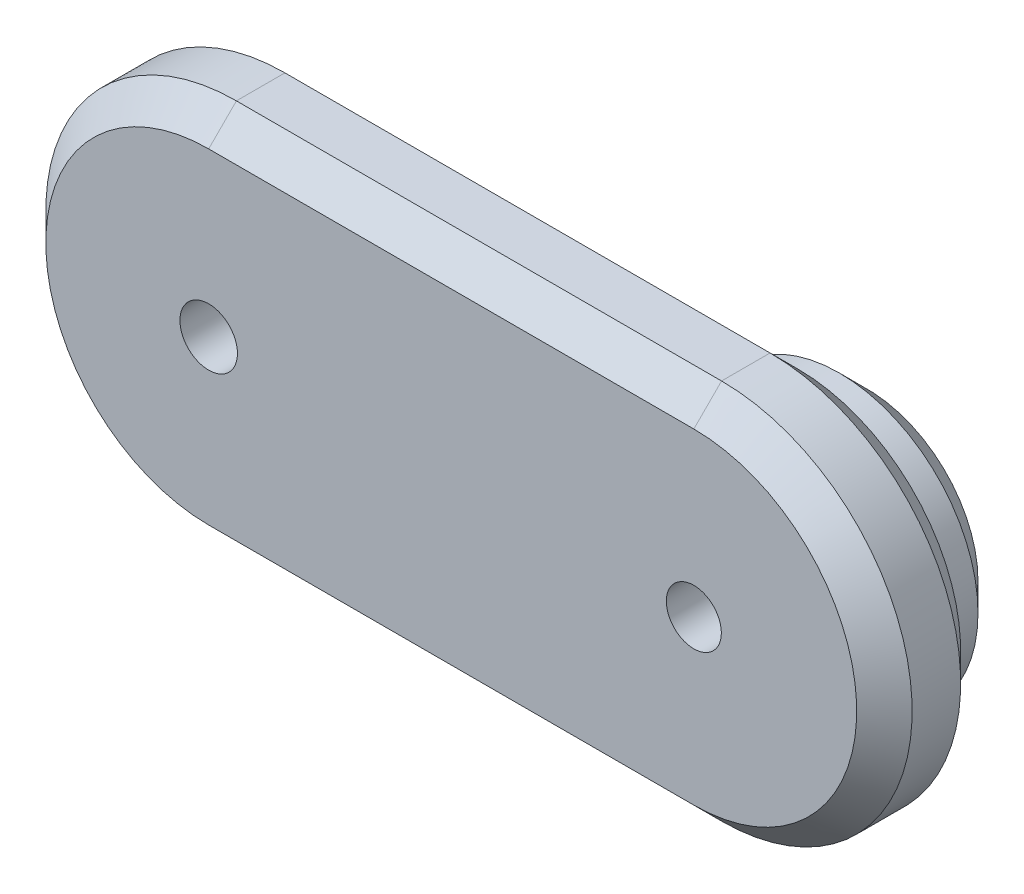
from build123d import *

# Parameters (mm, degrees)
SKETCH2_R           = 4.15
SKETCH2_R_2         = 3.96875
BOSS_EXTRUDE1_DEPTH = 15
SKETCH3_R           = 2.25
BOSS_EXTRUDE2_DEPTH = 2.25
CHAMFER1_SIZE       = 1.5
SKETCH5_R           = 20
SKETCH5_R_2         = 3.96875
BOSS_EXTRUDE4_DEPTH = 10
CHAMFER2_SIZE       = 4
CHAMFER3_SIZE       = 4


with BuildPart() as part:
    # Sketch2 → Boss-Extrude1 (new body)
    with BuildSketch(Plane.XY):
        with BuildLine():
            Line((70, 27.5), (0, 27.5))
            ThreePointArc((0, 27.5), (-27.5, 0), (0, -27.5))
            Line((0, -27.5), (70, -27.5))
            ThreePointArc((70, -27.5), (97.5, 0), (70, 27.5))
        make_face()
        Circle(SKETCH2_R, mode=Mode.SUBTRACT)
        with Locations((70, 0)):
            Circle(SKETCH2_R_2, mode=Mode.SUBTRACT)
    extrude(amount=BOSS_EXTRUDE1_DEPTH)

    # Sketch3 → Boss-Extrude2 (add)
    with BuildSketch(Plane(origin=(0, 0, 0), x_dir=(-1, 0, 0), z_dir=(0, 0, -1))):
        with Locations((-18, 0)):
            Circle(SKETCH3_R)
        with Locations((-16.217439622, 7.809907304)):
            Circle(SKETCH3_R)
        with Locations((-11.222816433, 14.072966684)):
            Circle(SKETCH3_R)
        with Locations((-4.005376811, 17.548702419)):
            Circle(SKETCH3_R)
        with Locations((4.005376811, 17.548702419)):
            Circle(SKETCH3_R)
        with Locations((11.222816433, 14.072966684)):
            Circle(SKETCH3_R)
        with Locations((16.217439622, 7.809907304)):
            Circle(SKETCH3_R)
        with Locations((18, 0)):
            Circle(SKETCH3_R)
        with Locations((16.217439622, -7.809907304)):
            Circle(SKETCH3_R)
        with Locations((11.222816433, -14.072966684)):
            Circle(SKETCH3_R)
        with Locations((4.005376811, -17.548702419)):
            Circle(SKETCH3_R)
        with Locations((-4.005376811, -17.548702419)):
            Circle(SKETCH3_R)
        with Locations((-11.222816433, -14.072966684)):
            Circle(SKETCH3_R)
        with Locations((-16.217439622, -7.809907304)):
            Circle(SKETCH3_R)
    extrude(amount=BOSS_EXTRUDE2_DEPTH)

    # Chamfer1
    chamfer1_edges = [part.edges().sort_by_distance(p)[0] for p in [
        (18.467439622, 7.809907304, -2.25),
        (13.472816433, 14.072966684, -2.25),
        (6.255376811, 17.548702419, -2.25),
        (-1.755376811, 17.548702419, -2.25),
        (-8.972816433, 14.072966684, -2.25),
        (-13.967439622, 7.809907304, -2.25),
        (-15.75, 0, -2.25),
        (-13.967439622, -7.809907304, -2.25),
        (-8.972816433, -14.072966684, -2.25),
        (-1.755376811, -17.548702419, -2.25),
        (6.255376811, -17.548702419, -2.25),
        (13.472816433, -14.072966684, -2.25),
        (18.467439622, -7.809907304, -2.25),
        (20.25, 0, -2.25),
    ]]
    chamfer(chamfer1_edges, length=CHAMFER1_SIZE)

    # Sketch5 → Boss-Extrude4 (add)
    with BuildSketch(Plane(origin=(0, 0, 0), x_dir=(-1, 0, 0), z_dir=(0, 0, -1))):
        with Locations((-70, 0)):
            Circle(SKETCH5_R)
        with Locations((-70, 0)):
            Circle(SKETCH5_R_2, mode=Mode.SUBTRACT)
    extrude(amount=BOSS_EXTRUDE4_DEPTH)

    # Chamfer2
    chamfer2_edges = [part.edges().sort_by_distance(p)[0] for p in [
        (90, 0, -10),
    ]]
    chamfer(chamfer2_edges, length=CHAMFER2_SIZE)

    # Chamfer3
    chamfer3_edges = [part.edges().sort_by_distance(p)[0] for p in [
        (-27.5, 0, 15),
        (35, -27.5, 15),
        (97.5, 0, 15),
        (35, -27.5, 0),
        (-27.5, 0, 0),
        (35, 27.5, 0),
        (97.5, 0, 0),
        (35, 27.5, 15),
    ]]
    chamfer(chamfer3_edges, length=CHAMFER3_SIZE)


solid = part.part
